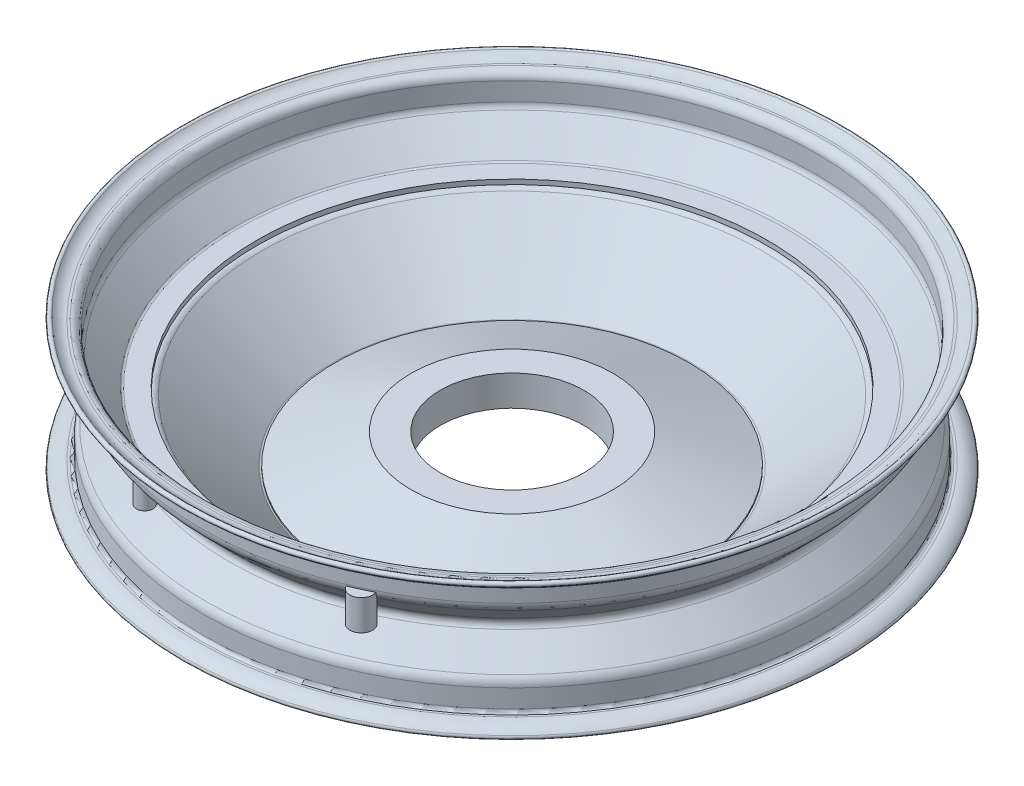
from build123d import *

# Parameters (mm, degrees)
SKETCH4_R               = 2.5
CUT_EXTRUDE3_DEPTH      = 42.595214206
CUT_EXTRUDE3_DEPTH_BACK = 49.124520078
SKETCH5_R               = 116.097179263
SKETCH5_R_2             = 47
BOSS_EXTRUDE1_DEPTH     = 20
SKETCH7_R               = 5.410205394
SKETCH7_R_2             = 7.403705909
BOSS_EXTRUDE2_DEPTH     = 20


with BuildPart() as part:
    # Sketch3 → Revolve2 (revolve)
    with BuildSketch(Plane.XY):
        with BuildLine():
            Line((-102, -48.124520078), (-116.097179263, -48.124520078))
            ThreePointArc((-116.097179263, -48.124520078), (-117.880721071, -47.803696603), (-119.440659096, -46.881448026))
            Line((-119.440659096, -46.881448026), (-165.983747962, -6.721764772))
            ThreePointArc((-165.983747962, -6.721764772), (-166.593336874, -6.361370643), (-167.290305146, -6.236))
            Line((-167.290305146, -6.236), (-180.049388931, -6.236))
            ThreePointArc((-180.049388931, -6.236), (-180.816787473, -6.396329067), (-181.463602494, -6.839314687))
            Line((-181.463602494, -6.839314687), (-198.251490932, -23.609067138))
            ThreePointArc((-198.251490932, -23.609067138), (-199.351899333, -25.212361847), (-199.739183475, -27.118001784))
            Line((-199.739183475, -27.118001784), (-199.739183475, -39.117999668))
            ThreePointArc((-199.739183475, -39.117999668), (-201.238210969, -42.736972174), (-204.857183475, -44.235999668))
            Line((-204.857183475, -44.235999668), (-206.357183497, -44.235999668))
            ThreePointArc((-206.357183497, -44.235999668), (-210.160078428, -45.041291982), (-213.310139828, -47.318926446))
            ThreePointArc((-213.310139828, -47.318926446), (-215.512219762, -47.4275817), (-215.620875016, -45.225501766))
            ThreePointArc((-215.620875016, -45.225501766), (-211.423926876, -42.190921638), (-206.357183475, -41.117999668))
            Line((-206.357183475, -41.117999668), (-204.857183475, -41.117999668))
            ThreePointArc((-204.857183475, -41.117999668), (-203.442969913, -40.53221323), (-202.857183475, -39.117999668))
            Line((-202.857183475, -39.117999668), (-202.857183475, -27.118001784))
            ThreePointArc((-202.857183475, -27.118001784), (-202.22255126, -23.995282756), (-200.41934243, -21.368008487))
            Line((-200.41934243, -21.368008487), (-185.35258838, -6.301254436))
            ThreePointArc((-185.35258838, -6.301254436), (-184.03404122, -3.118), (-185.35258838, 0.065254437))
            Line((-185.35258838, 0.065254437), (-200.41934243, 15.132008487))
            ThreePointArc((-200.41934243, 15.132008487), (-202.22255126, 17.759282757), (-202.857183476, 20.882001784))
            Line((-202.857183476, 20.882001784), (-202.857183476, 32.881999668))
            ThreePointArc((-202.857183476, 32.881999668), (-203.442969914, 34.296213231), (-204.857183476, 34.881999668))
            Line((-204.857183476, 34.881999668), (-206.357183476, 34.881999668))
            ThreePointArc((-206.357183476, 34.881999668), (-211.423926877, 35.954921638), (-215.620875017, 38.989501766))
            ThreePointArc((-215.620875017, 38.989501766), (-215.512219763, 41.1915817), (-213.310139829, 41.082926446))
            ThreePointArc((-213.310139829, 41.082926446), (-210.16007843, 38.805291983), (-206.357183499, 37.999999668))
            Line((-206.357183499, 37.999999668), (-204.857183476, 37.999999668))
            ThreePointArc((-204.857183476, 37.999999668), (-201.23821097, 36.500972175), (-199.739183476, 32.881999668))
            Line((-199.739183476, 32.881999668), (-199.739183476, 20.882001784))
            ThreePointArc((-199.739183476, 20.882001784), (-199.351809516, 18.976419568), (-198.251353913, 17.373204164))
            Line((-198.251353913, 17.373204164), (-181.463769341, 0.585619592))
            ThreePointArc((-181.463769341, 0.585619592), (-180.814826345, 0.152131935), (-180.049388931, 0))
            Line((-180.049388931, 0), (-167.290305146, 0))
            Line((-167.290305146, 0), (-167.290305146, -3.118))
            ThreePointArc((-167.290305146, -3.118), (-165.506763338, -3.438823474), (-163.946825313, -4.361072052))
            Line((-163.946825313, -4.361072052), (-117.403736447, -44.520755305))
            ThreePointArc((-117.403736447, -44.520755305), (-116.794147535, -44.881149435), (-116.097179263, -45.006520077))
            Line((-116.097179263, -45.006520077), (-102, -45.006520077))
            Line((-102, -45.006520077), (-102, -48.124520078))
        make_face()
    revolve(axis=Axis((0, 240.888952165, 0), (0, -1, 0)))

    # Sketch4 → Cut-Extrude3 (cut, two sides)
    with BuildSketch(Plane(origin=(0, 0, 0), x_dir=(1, 0, 0), z_dir=(0, 1, 0))) as cut_extrude3_sk:
        with Locations((0, 107)):
            Circle(SKETCH4_R)
        with Locations((-3884.181572475, -9484.24383099)):
            Circle(SKETCH4_R)
        with Locations((-13412.746254639, -13519.746254639)):
            Circle(SKETCH4_R)
        with Locations((-23003.990085629, -9635.564682164)):
            Circle(SKETCH4_R)
        with Locations((-27039.492509279, -107)):
            Circle(SKETCH4_R)
        with Locations((-23155.310936803, 9484.24383099)):
            Circle(SKETCH4_R)
        with Locations((-13626.746254639, 13519.746254639)):
            Circle(SKETCH4_R)
        with Locations((-4035.502423649, 9635.564682164)):
            Circle(SKETCH4_R)
        with Locations((-20.874664456, 104.944025003)):
            Circle(SKETCH4_R)
        with Locations((-3900.395983129, -9470.93700806)):
            Circle(SKETCH4_R)
        with Locations((-13414.802229636, -13498.871590184)):
            Circle(SKETCH4_R)
        with Locations((-22990.6832627, -9619.35027151)):
            Circle(SKETCH4_R)
        with Locations((-27018.617844823, -104.944025003)):
            Circle(SKETCH4_R)
        with Locations((-23139.096526149, 9470.93700806)):
            Circle(SKETCH4_R)
        with Locations((-13624.690279642, 13498.871590184)):
            Circle(SKETCH4_R)
        with Locations((-4048.809246579, 9619.35027151)):
            Circle(SKETCH4_R)
        with Locations((75.660425587, 75.660425587)):
            Circle(SKETCH4_R)
        with Locations((59.446014933, 88.967248516)):
            Circle(SKETCH4_R)
        with Locations((107, 0)):
            Circle(SKETCH4_R)
        with Locations((104.944025003, 20.874664456)):
            Circle(SKETCH4_R)
        with Locations((75.660425587, -75.660425587)):
            Circle(SKETCH4_R)
        with Locations((88.967248516, -59.446014933)):
            Circle(SKETCH4_R)
        with Locations((0, -107)):
            Circle(SKETCH4_R)
        with Locations((20.874664456, -104.944025003)):
            Circle(SKETCH4_R)
        with Locations((-75.660425587, -75.660425587)):
            Circle(SKETCH4_R)
        with Locations((-59.446014933, -88.967248516)):
            Circle(SKETCH4_R)
        with Locations((-107, 0)):
            Circle(SKETCH4_R)
        with Locations((-104.944025003, -20.874664456)):
            Circle(SKETCH4_R)
        with Locations((-75.660425587, 75.660425587)):
            Circle(SKETCH4_R)
        with Locations((-88.967248516, 59.446014933)):
            Circle(SKETCH4_R)
    extrude(amount=CUT_EXTRUDE3_DEPTH, mode=Mode.SUBTRACT)
    extrude(cut_extrude3_sk.sketch, amount=-CUT_EXTRUDE3_DEPTH_BACK, mode=Mode.SUBTRACT)

    # Sketch5 → Boss-Extrude1 (add)
    with BuildSketch(Plane(origin=(0, -45.006520077, 0), x_dir=(1, 0, 0), z_dir=(0, 1, 0))):
        Circle(SKETCH5_R)
        Circle(SKETCH5_R_2, mode=Mode.SUBTRACT)
    extrude(amount=BOSS_EXTRUDE1_DEPTH)

    # Sketch7 → Boss-Extrude2 (add)
    with BuildSketch(Plane(origin=(0, 0, 0), x_dir=(1, 0, 0), z_dir=(0, 1, 0))):
        with Locations((-54.139599457, -186.635086447)):
            Circle(SKETCH7_R)
        with Locations((84.67988633, -183.550208985)):
            Circle(SKETCH7_R_2)
    extrude(amount=BOSS_EXTRUDE2_DEPTH)

    # Sketch8 → Cut-Revolve1 (revolve, cut)
    with BuildSketch(Plane(origin=(0, 0, 0), x_dir=(0, 0, -1), z_dir=(1, 0, 0))):
        Polygon((17.818466603, -21.471321618), (56.892581496, -21.471321618), (117.403736447, -44.520755305), (117.403736447, 14.096166333), (17.818466603, 14.096166333), align=None)
    revolve(axis=Axis((0, 240.888952165, 0), (0, -1, 0)), mode=Mode.SUBTRACT)


solid = part.part
